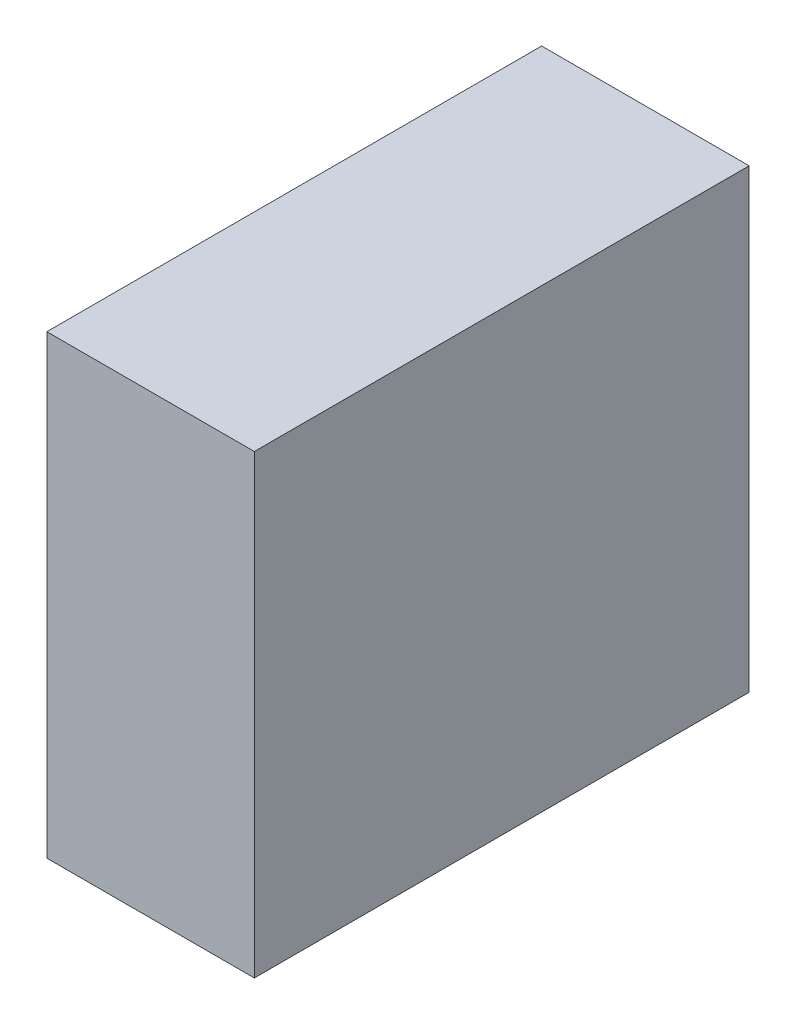
from build123d import *

# Parameters (mm, degrees)
SKETCH1_W           = 75.946
SKETCH1_H           = 181.102
BOSS_EXTRUDE1_DEPTH = 166.878


with BuildPart() as part:
    # Sketch1 → Boss-Extrude1 (new body)
    with BuildSketch(Plane(origin=(0, 0, 0), x_dir=(1, 0, 0), z_dir=(0, 1, 0))):
        with Locations((37.973, 90.551)):
            Rectangle(SKETCH1_W, SKETCH1_H)
    extrude(amount=BOSS_EXTRUDE1_DEPTH)


solid = part.part
